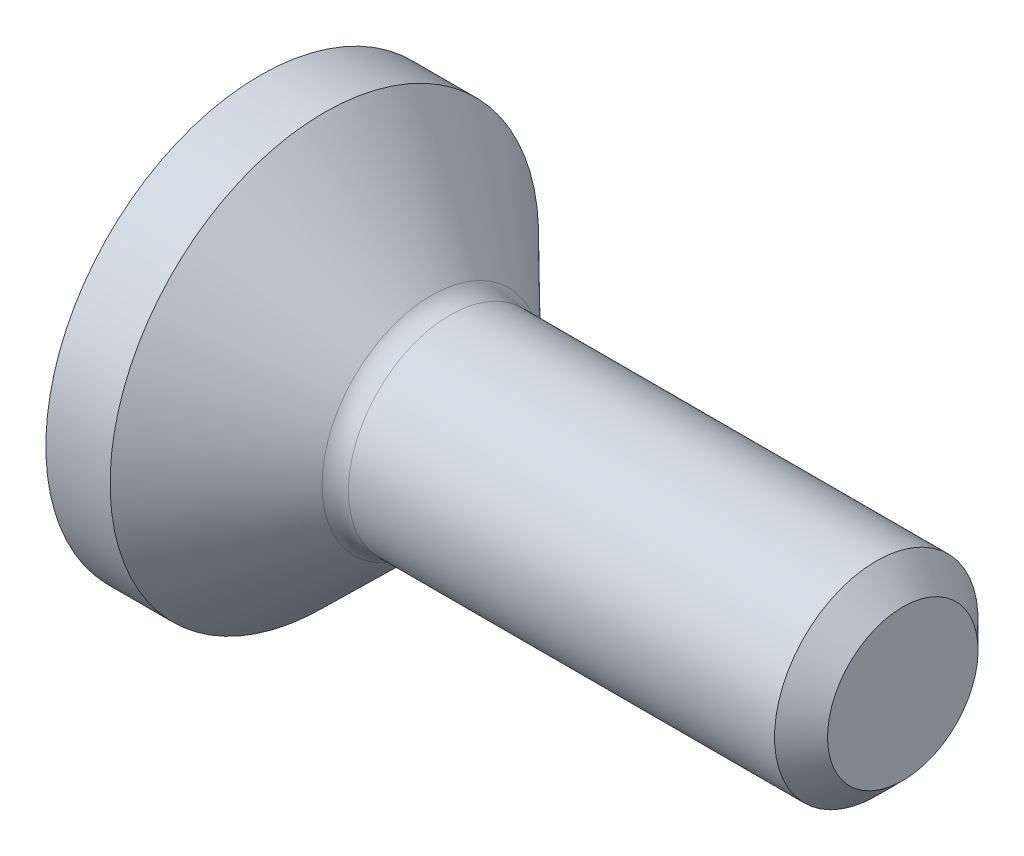
from build123d import *

# Parameters (mm, degrees)
CUT_EXTRUDE1_DEPTH = 1.5


with BuildPart() as part:
    # Sketch1 → Revolve1 (revolve)
    with BuildSketch(Plane.XY):
        with BuildLine():
            Line((1.774861053, 0.95), (5.752512627, 0.95))
            Line((5.752512627, 0.95), (6, 0.702512627))
            Line((6, 0.702512627), (6, 0))
            Line((6, 0), (0, 0))
            Line((0, 0), (0, 2))
            Line((0, 2), (0.6, 2))
            Line((0.6, 2), (1.6, 1.0213282))
            ThreePointArc((1.6, 1.0213282), (1.680436347, 0.968517873), (1.774861053, 0.95))
        make_face()
    revolve(axis=Axis((0, 0, 0), (-1, 0, 0)))

    # Sketch2 → Cut-Extrude1 (cut)
    with BuildSketch(Plane.ZY):
        Polygon((0.75, 0.433012702), (0, 0.866025404), (-0.75, 0.433012702), (-0.75, -0.433012702), (0, -0.866025404), (0.75, -0.433012702), align=None)
    extrude(amount=-CUT_EXTRUDE1_DEPTH, mode=Mode.SUBTRACT)


solid = part.part
